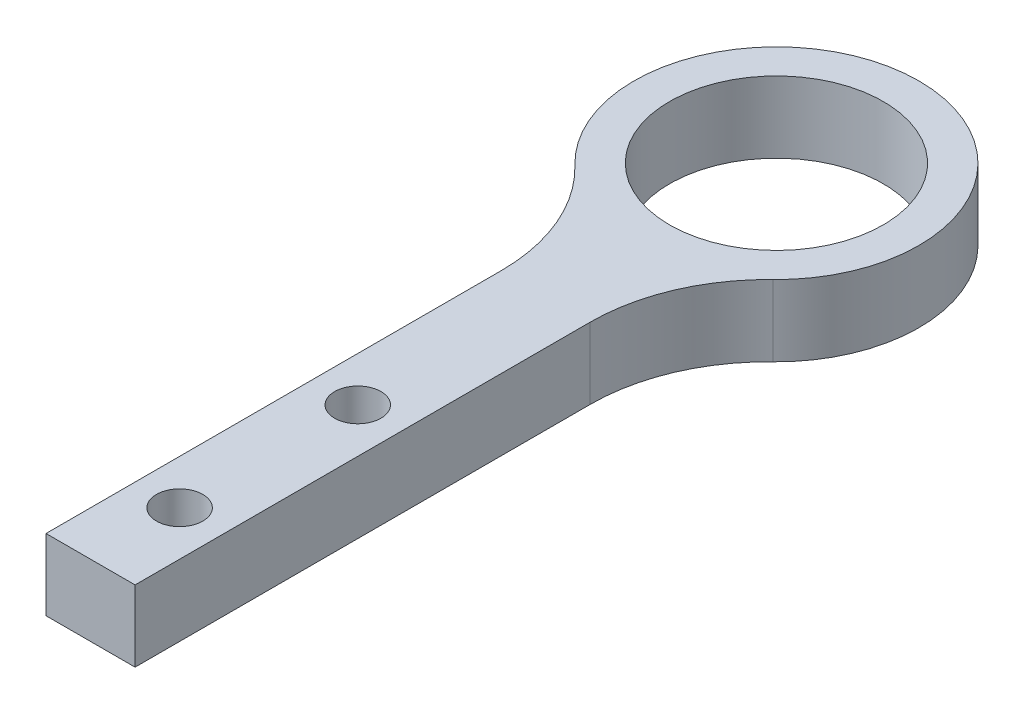
from build123d import *

# Parameters (mm, degrees)
SKETCH1_R                                       = 6
BOSS_EXTRUDE1_DEPTH                             = 4
CSK_FOR_M2_FLAT_HEAD_MACHINE_SCREW1_D           = 2.6
CSK_FOR_M2_FLAT_HEAD_MACHINE_SCREW1_CSINK_D     = 4.4
CSK_FOR_M2_FLAT_HEAD_MACHINE_SCREW1_CSINK_ANGLE = 90


with BuildPart() as part:
    # Sketch1 → Boss-Extrude1 (new body)
    with BuildSketch(Plane(origin=(0, 0, 0), x_dir=(1, 0, 0), z_dir=(0, 1, 0))):
        with BuildLine():
            Line((-2.5, -12.951833847), (-2.5, -38.5))
            Line((-2.5, -38.5), (2.5, -38.5))
            Line((2.5, -38.5), (2.5, -12.951833847))
            ThreePointArc((2.5, -12.951833847), (3.295532486, -9.043154047), (5.555555556, -5.756370599))
            ThreePointArc((5.555555556, -5.756370599), (0, 8), (-5.555555556, -5.756370599))
            ThreePointArc((-5.555555556, -5.756370599), (-3.295532486, -9.043154047), (-2.5, -12.951833847))
        make_face()
        Circle(SKETCH1_R, mode=Mode.SUBTRACT)
    extrude(amount=BOSS_EXTRUDE1_DEPTH)

    # CSK for M2 Flat Head Machine Screw1 (through all)
    with Locations(Plane(origin=(0, 0, 0), x_dir=(-1, 0, 0), z_dir=(0, -1, 0))):
        with Locations((0, -23.5), (0, -33.5)):
            CounterSinkHole(CSK_FOR_M2_FLAT_HEAD_MACHINE_SCREW1_D / 2, CSK_FOR_M2_FLAT_HEAD_MACHINE_SCREW1_CSINK_D / 2, counter_sink_angle=CSK_FOR_M2_FLAT_HEAD_MACHINE_SCREW1_CSINK_ANGLE)


solid = part.part
